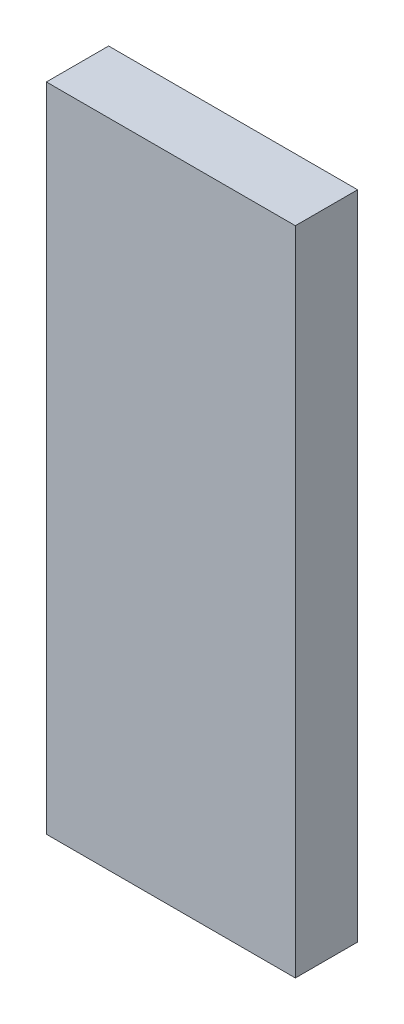
from build123d import *

# Parameters (mm, degrees)
SKETCH1_W           = 60
SKETCH1_H           = 157
BOSS_EXTRUDE1_DEPTH = 15


with BuildPart() as part:
    # Sketch1 → Boss-Extrude1 (new body)
    with BuildSketch(Plane.XY):
        with Locations((30, 78.5)):
            Rectangle(SKETCH1_W, SKETCH1_H)
    extrude(amount=BOSS_EXTRUDE1_DEPTH)


solid = part.part
